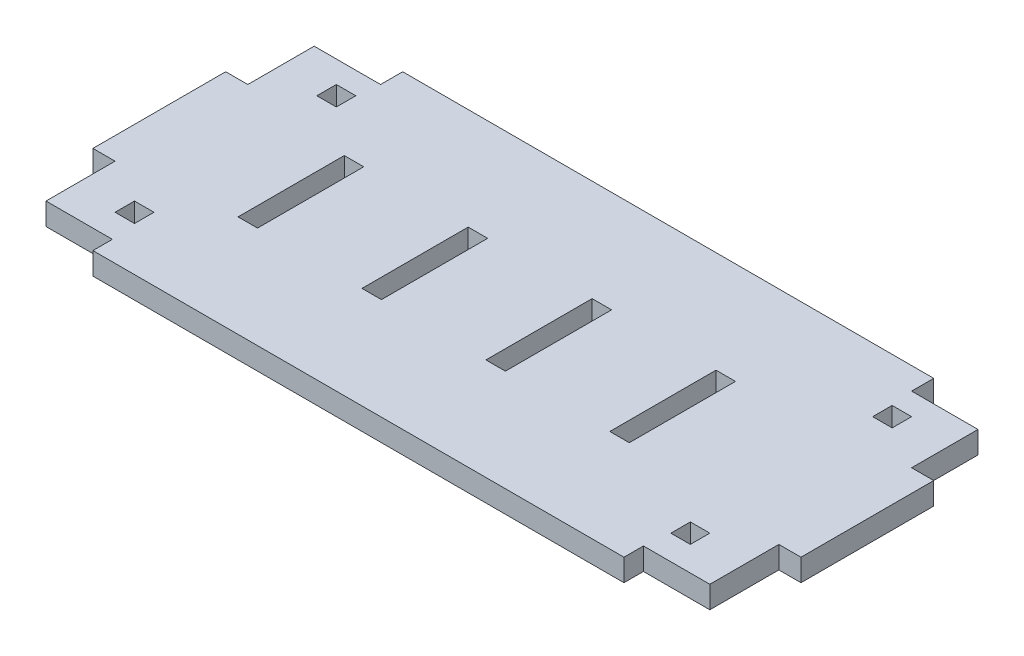
from build123d import *

# Parameters (mm, degrees)
SKETCH1_W               = 190.5
SKETCH1_H               = 88.9
BOSS_EXTRUDE1_DEPTH     = 6.35
SKETCH2_W               = 5.588
SKETCH2_H               = 30.48
HOLE_DEPTH              = 6.35
SKETCH3_W               = 38.1
SKETCH3_H               = 6.35
TAB1_DEPTH              = 6.35
SKETCH4_W               = 38.1
SKETCH4_H               = 6.35
TAB2_DEPTH              = 6.35
SKETCH5_W               = 5.588
SKETCH5_H               = 5.588
DOWEL1_DEPTH            = 6.35
MIRROR2_COPY_1_SKETCH_W = 5.588
MIRROR2_COPY_1_SKETCH_H = 5.588
MIRROR2_COPY_1_DEPTH    = 6.35
SKETCH6_W               = 19.05
SKETCH6_H               = 5.588
SKETCH6_H_2             = 6.35
CUT_EXTRUDE1_DEPTH      = 7.35


with BuildPart() as part:
    # Sketch1 → Boss-Extrude1 (new body)
    with BuildSketch(Plane(origin=(0, 0, 0), x_dir=(1, 0, 0), z_dir=(0, 1, 0))):
        Rectangle(SKETCH1_W, SKETCH1_H)
    extrude(amount=BOSS_EXTRUDE1_DEPTH)

    # Sketch2 → hole (cut)
    with BuildSketch(Plane(origin=(0, 6.35, 0), x_dir=(1, 0, 0), z_dir=(0, 1, 0))):
        with Locations((-60.96, 0)):
            Rectangle(SKETCH2_W, SKETCH2_H)
        with Locations((-25.4, 0)):
            Rectangle(SKETCH2_W, SKETCH2_H)
        with Locations((10.16, 0)):
            Rectangle(SKETCH2_W, SKETCH2_H)
        with Locations((45.72, 0)):
            Rectangle(SKETCH2_W, SKETCH2_H)
    extrude(amount=-HOLE_DEPTH, mode=Mode.SUBTRACT)

    # Sketch3 → tab1 (add)
    with BuildSketch(Plane.ZY.offset(95.25)):
        with Locations((0, 3.175)):
            Rectangle(SKETCH3_W, SKETCH3_H)
    extrude(amount=TAB1_DEPTH)

    # Sketch4 → tab2 (add)
    with BuildSketch(Plane(origin=(95.25, 0, 0), x_dir=(0, 0, -1), z_dir=(1, 0, 0))):
        with Locations((0, 3.175)):
            Rectangle(SKETCH4_W, SKETCH4_H)
    extrude(amount=TAB2_DEPTH)

    # Sketch5 → dowel1 (cut)
    with BuildSketch(Plane(origin=(0, 6.35, 0), x_dir=(1, 0, 0), z_dir=(0, 1, 0))):
        with Locations((-79.756, 28.956)):
            Rectangle(SKETCH5_W, SKETCH5_H)
    dowel1 = extrude(amount=-DOWEL1_DEPTH, mode=Mode.SUBTRACT)

    # Mirror1: dowel1 across plane
    add(dowel1.mirror(Plane(origin=(0, 0, 0), x_dir=(0, 0, 1), z_dir=(1, 0, 0))), mode=Mode.SUBTRACT)

    # Mirror2: dowel1 across plane
    add(dowel1.mirror(Plane.XY), mode=Mode.SUBTRACT)

    # Mirror2 copy 1 sketch → Mirror2 copy 1 (cut)
    with BuildSketch(Plane(origin=(0, 6.35, 0), x_dir=(-1, 0, 0), z_dir=(0, 1, 0))):
        with Locations((-79.756, 28.956)):
            Rectangle(MIRROR2_COPY_1_SKETCH_W, MIRROR2_COPY_1_SKETCH_H)
    extrude(amount=-MIRROR2_COPY_1_DEPTH, mode=Mode.SUBTRACT)

    # Sketch6 → Cut-Extrude1 (cut, through all)
    with BuildSketch(Plane(origin=(0, 6.35, 0), x_dir=(1, 0, 0), z_dir=(0, 1, 0))):
        with Locations((-85.725, -41.656)):
            Rectangle(SKETCH6_W, SKETCH6_H)
        with Locations((85.725, -41.656)):
            Rectangle(SKETCH6_W, SKETCH6_H)
        with Locations((-85.725, 41.275)):
            Rectangle(SKETCH6_W, SKETCH6_H_2)
        with Locations((85.725, 41.275)):
            Rectangle(SKETCH6_W, SKETCH6_H_2)
    extrude(amount=-CUT_EXTRUDE1_DEPTH, mode=Mode.SUBTRACT)


solid = part.part
